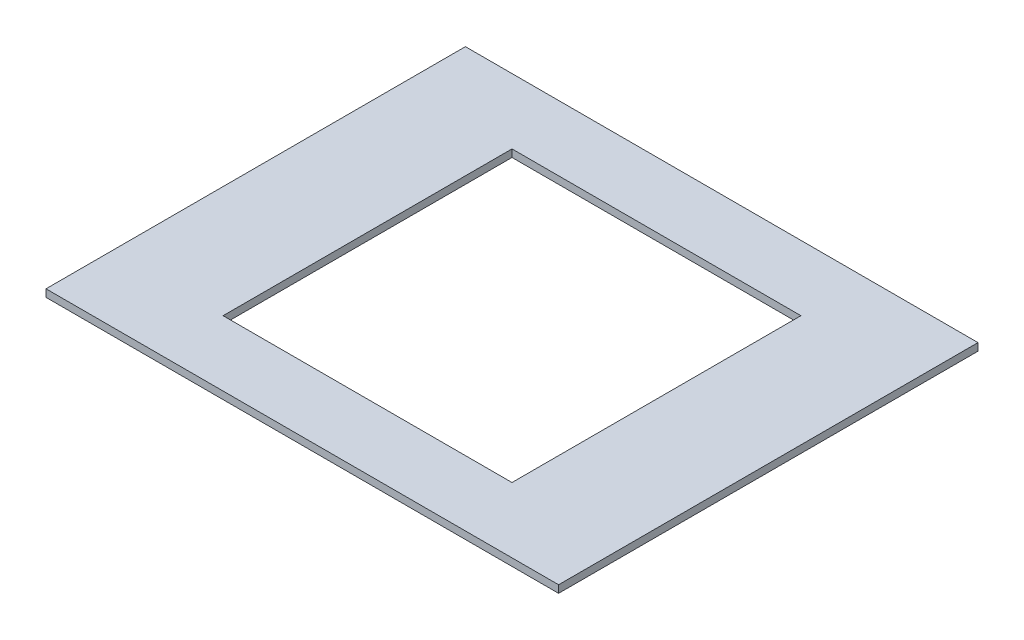
from build123d import *

# Parameters (mm, degrees)
SKETCH1_W           = 110
SKETCH1_H           = 90
BOSS_EXTRUDE1_DEPTH = 1.6
CUT_EXTRUDE1_DEPTH  = 1.6


with BuildPart() as part:
    # Sketch1 → Boss-Extrude1 (new body)
    with BuildSketch(Plane(origin=(0, 0, 0), x_dir=(1, 0, 0), z_dir=(0, 1, 0))):
        with Locations((55, 45)):
            Rectangle(SKETCH1_W, SKETCH1_H)
    extrude(amount=BOSS_EXTRUDE1_DEPTH)

    # Sketch2 → Cut-Extrude1 (cut)
    with BuildSketch(Plane(origin=(0, 1.6, 0), x_dir=(1, 0, 0), z_dir=(0, 1, 0))):
        Polygon((55, 76), (86, 76), (86, 45), (86, 14), (55, 14), (24, 14), (24, 45), (24, 76), align=None)
    extrude(amount=-CUT_EXTRUDE1_DEPTH, mode=Mode.SUBTRACT)


solid = part.part
